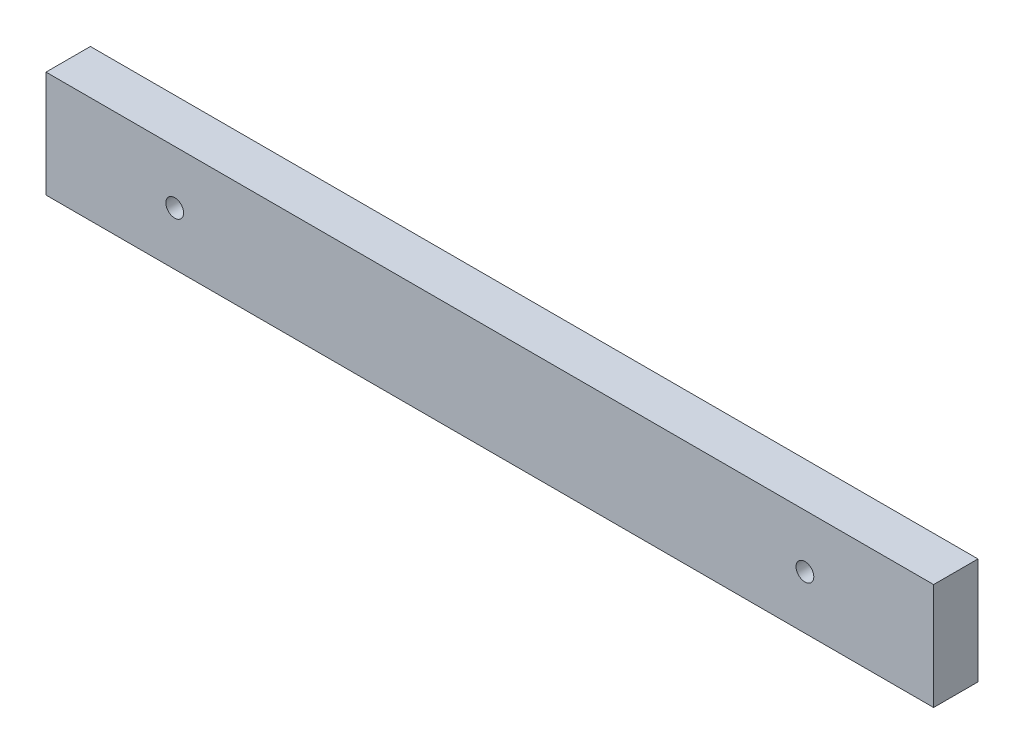
from build123d import *

# Parameters (mm, degrees)
SKETCH1_W           = 100
SKETCH1_H           = 12
BOSS_EXTRUDE1_DEPTH = 5
SKETCH2_R           = 1
CUT_EXTRUDE1_DEPTH  = 6


with BuildPart() as part:
    # Sketch1 → Boss-Extrude1 (new body)
    with BuildSketch(Plane.XY):
        with Locations((50, 6)):
            Rectangle(SKETCH1_W, SKETCH1_H)
    extrude(amount=BOSS_EXTRUDE1_DEPTH)

    # Sketch2 → Cut-Extrude1 (cut, through all)
    with BuildSketch(Plane.XY.offset(5)):
        with Locations((14.5, 6)):
            Circle(SKETCH2_R)
        with Locations((85.5, 6)):
            Circle(SKETCH2_R)
    extrude(amount=-CUT_EXTRUDE1_DEPTH, mode=Mode.SUBTRACT)


solid = part.part
